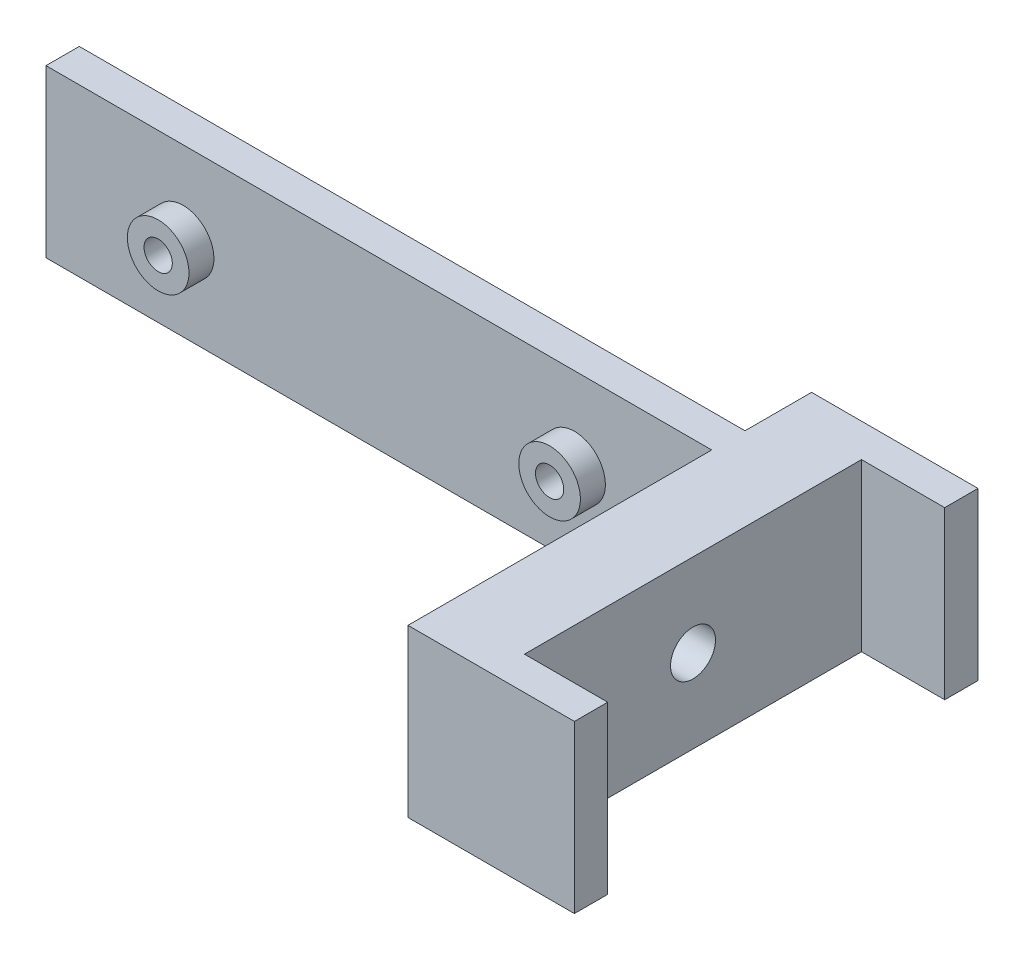
from build123d import *

# Parameters (mm, degrees)
SKETCH1_W           = 80
SKETCH1_H           = 4
SKETCH1_W_2         = 10
BOSS_EXTRUDE1_DEPTH = 20
CUT_EXTRUDE2_REACH  = 92
SKETCH2_R           = 2.7
CUT_EXTRUDE3_REACH  = 14
SKETCH4_R           = 1.7
SKETCH5_R           = 3.7
SKETCH5_R_2         = 1.7
BOSS_EXTRUDE2_DEPTH = 3
SKETCH6_R           = 4.3
CUT_EXTRUDE4_DEPTH  = 5
CUT_EXTRUDE5_DEPTH  = 3


with BuildPart() as part:
    # Sketch1 → Boss-Extrude1 (new body)
    with BuildSketch(Plane(origin=(0, 0, 0), x_dir=(1, 0, 0), z_dir=(0, 1, 0))):
        with Locations((40, -2)):
            Rectangle(SKETCH1_W, SKETCH1_H)
        Polygon((80, 8), (80, 0), (80, -4), (80, -40.5), (90, -40.5), (90, -36.5), (90, 4), (90, 8), align=None)
        with Locations((95, 6)):
            Rectangle(SKETCH1_W_2, SKETCH1_H)
        with Locations((95, -38.5)):
            Rectangle(SKETCH1_W_2, SKETCH1_H)
    extrude(amount=BOSS_EXTRUDE1_DEPTH)

    # Sketch2 → Cut-Extrude2 (cut, up to next)
    with BuildSketch(Plane(origin=(90, 0, 0), x_dir=(0, 0, -1), z_dir=(1, 0, 0)), mode=Mode.PRIVATE) as cut_extrude2_sk1:
        with Locations((-16.25, 10)):
            Circle(SKETCH2_R)
    cut_extrude2_tool1 = extrude(cut_extrude2_sk1.sketch, amount=-CUT_EXTRUDE2_REACH, mode=Mode.PRIVATE) & part.part
    add(cut_extrude2_tool1.solids().sort_by_distance((90, 10, 16.25))[0], mode=Mode.SUBTRACT)

    # Sketch4 → Cut-Extrude3 (cut, up to next)
    with BuildSketch(Plane.XY.offset(4), mode=Mode.PRIVATE) as cut_extrude3_sk1:
        with Locations((16.48, 10)):
            Circle(SKETCH4_R)
    cut_extrude3_tool1 = extrude(cut_extrude3_sk1.sketch, amount=-CUT_EXTRUDE3_REACH, mode=Mode.PRIVATE) & part.part
    add(cut_extrude3_tool1.solids().sort_by_distance((16.48, 10, 4))[0], mode=Mode.SUBTRACT)
    # Sketch4 → Cut-Extrude3 (cut, up to next)
    with BuildSketch(Plane.XY.offset(4), mode=Mode.PRIVATE) as cut_extrude3_sk2:
        with Locations((63.52, 10)):
            Circle(SKETCH4_R)
    cut_extrude3_tool2 = extrude(cut_extrude3_sk2.sketch, amount=-CUT_EXTRUDE3_REACH, mode=Mode.PRIVATE) & part.part
    add(cut_extrude3_tool2.solids().sort_by_distance((63.52, 10, 4))[0], mode=Mode.SUBTRACT)

    # Sketch5 → Boss-Extrude2 (add)
    with BuildSketch(Plane.XY.offset(4)):
        with Locations((16.48, 10)):
            Circle(SKETCH5_R)
        with Locations((16.48, 10)):
            Circle(SKETCH5_R_2, mode=Mode.SUBTRACT)
        with Locations((63.52, 10)):
            Circle(SKETCH5_R)
        with Locations((63.52, 10)):
            Circle(SKETCH5_R_2, mode=Mode.SUBTRACT)
    extrude(amount=BOSS_EXTRUDE2_DEPTH)

    # Sketch6 → Cut-Extrude4 (cut)
    with BuildSketch(Plane.ZY.offset(-80)):
        with Locations((16.25, 10)):
            Circle(SKETCH6_R)
    extrude(amount=-CUT_EXTRUDE4_DEPTH, mode=Mode.SUBTRACT)

    # Sketch7 → Cut-Extrude5 (cut)
    with BuildSketch(Plane(origin=(0, 0, 0), x_dir=(-1, 0, 0), z_dir=(0, 0, -1))):
        Polygon((-60.77, 8.41228676), (-60.77, 11.58771324), (-63.52, 13.175426481), (-66.27, 11.58771324), (-66.27, 8.41228676), (-63.52, 6.824573519), align=None)
        Polygon((-13.73, 8.41228676), (-13.73, 11.58771324), (-16.48, 13.175426481), (-19.23, 11.58771324), (-19.23, 8.41228676), (-16.48, 6.824573519), align=None)
    extrude(amount=-CUT_EXTRUDE5_DEPTH, mode=Mode.SUBTRACT)


solid = part.part
